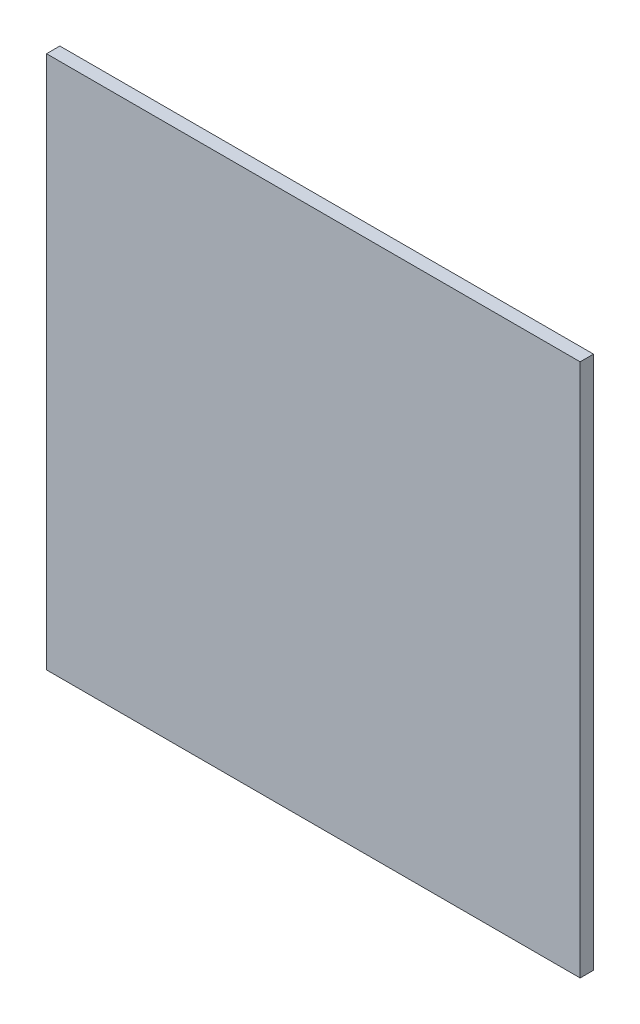
from build123d import *

# Parameters (mm, degrees)
SKETCH1_W           = 400
SKETCH1_H           = 400
BOSS_EXTRUDE1_DEPTH = 10


with BuildPart() as part:
    # Sketch1 → Boss-Extrude1 (new body)
    with BuildSketch(Plane.XY):
        with Locations((-81.841613289, -115.141590889)):
            Rectangle(SKETCH1_W, SKETCH1_H)
    extrude(amount=BOSS_EXTRUDE1_DEPTH)


solid = part.part
